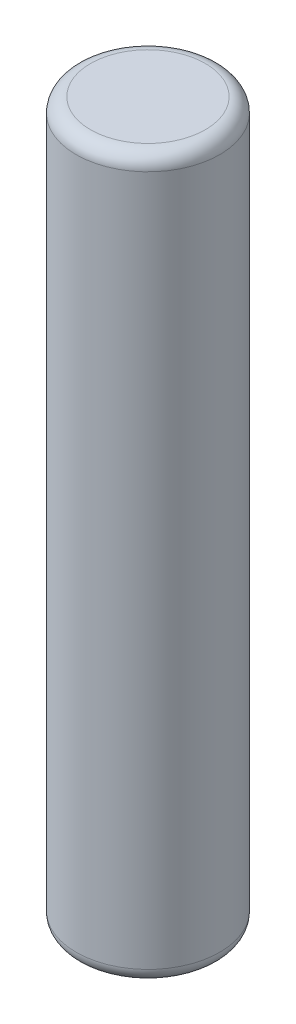
from build123d import *

# Parameters (mm, degrees)
SKETCH1_R           = 4.99
BOSS_EXTRUDE1_DEPTH = 50
FILLET1_R           = 1


with BuildPart() as part:
    # Sketch1 → Boss-Extrude1 (new body)
    with BuildSketch(Plane(origin=(0, 0, 0), x_dir=(1, 0, 0), z_dir=(0, 1, 0))):
        Circle(SKETCH1_R)
    extrude(amount=BOSS_EXTRUDE1_DEPTH)

    # Fillet1
    fillet1_edges = [part.edges().sort_by_distance(p)[0] for p in [
        (-4.99, 0, 0),
        (-4.99, 50, 0),
    ]]
    fillet(fillet1_edges, radius=FILLET1_R)


solid = part.part
